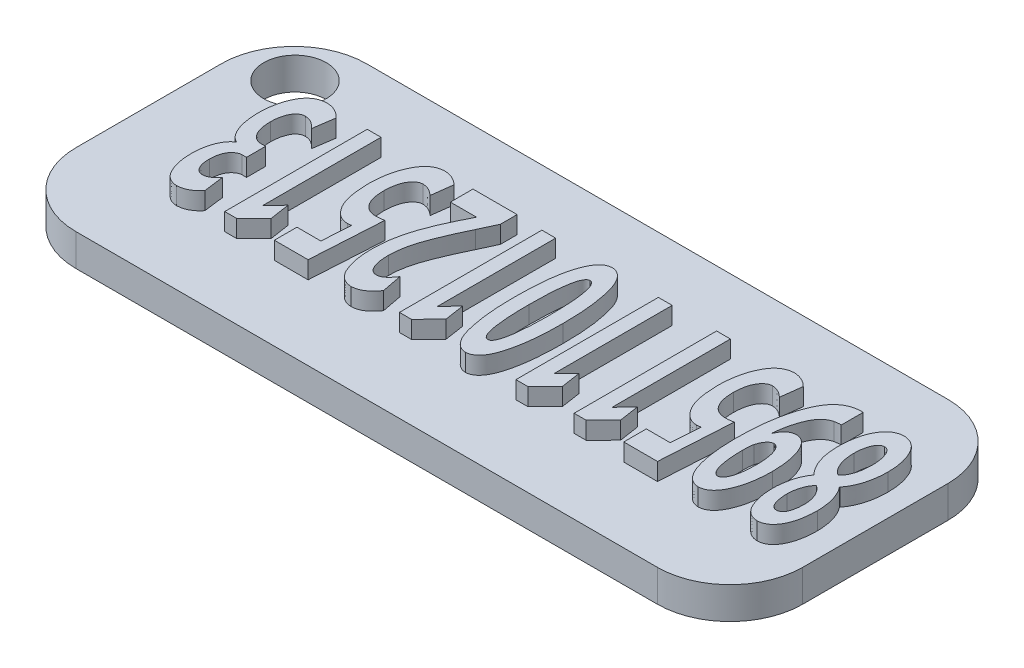
from build123d import *

# Parameters (mm, degrees)
SKETCH_1_W              = 50
SKETCH_1_H              = 20
EXTRUDE_1_DEPTH         = 2.2
FILLET_1_R              = 5
FILLET_2_R              = 5
FILLET_3_R              = 5
FILLET_4_R              = 5
SKETCH_4_R              = 2.151855383
CUT_EXTRUDE_1_DEPTH     = 3
EXTRUDE_1054_DEPTH      = 1.2
EXTRUDE_1054_DEPTH_BACK = 1.2


with BuildPart() as part:
    # Эскиз1 → Бобышка-Вытянуть1 (new body)
    with BuildSketch(Plane(origin=(0, 0, 0), x_dir=(1, 0, 0), z_dir=(0, 1, 0))):
        with Locations((25, 10)):
            Rectangle(SKETCH_1_W, SKETCH_1_H)
    extrude(amount=EXTRUDE_1_DEPTH)

    # Скругление1
    fillet_1_edges = [part.edges().sort_by_distance(p)[0] for p in [
        (0, 1.1, -20),
    ]]
    fillet(fillet_1_edges, radius=FILLET_1_R)

    # Скругление2
    fillet_2_edges = [part.edges().sort_by_distance(p)[0] for p in [
        (0, 1.1, 0),
    ]]
    fillet(fillet_2_edges, radius=FILLET_2_R)

    # Скругление3
    fillet_3_edges = [part.edges().sort_by_distance(p)[0] for p in [
        (50, 1.1, -20),
    ]]
    fillet(fillet_3_edges, radius=FILLET_3_R)

    # Скругление4
    fillet_4_edges = [part.edges().sort_by_distance(p)[0] for p in [
        (50, 1.1, 0),
    ]]
    fillet(fillet_4_edges, radius=FILLET_4_R)

    # Эскиз4 → Вырез-Вытянуть1 (cut)
    with BuildSketch(Plane(origin=(0, 2.2, 0), x_dir=(1, 0, 0), z_dir=(0, 1, 0))):
        with Locations((3.542470198, 16.528352227)):
            Circle(SKETCH_4_R)
    extrude(amount=-CUT_EXTRUDE_1_DEPTH, mode=Mode.SUBTRACT)

    # Эскиз5 → Extrude 1054 (add, two sides: drawn at the far end of the back side and taken through both)
    # profile 1 of 11: a face of its own
    with BuildSketch(Plane.XZ.offset(-2.2).offset(-EXTRUDE_1054_DEPTH_BACK)):
        with BuildLine():
            add(Edge.make_bspline(
                [(46.078309947, -9.677843866), (46.027974113, -9.605172508), (45.925734825, -9.457566573), (45.797719515, -9.21403545), (45.690766361, -8.949790128), (45.605330166, -8.667262078), (45.538818282, -8.374682095), (45.489532793, -8.076942657), (45.45786786, -7.777208198), (45.454564992, -7.576119586), (45.452912137, -7.475488811)],
                knots=[0, 0, 0, 0, 0.911528828, 1.851445597, 2.831681584, 3.849114504, 4.893651631, 5.925632796, 6.961924405, 8, 8, 8, 8], degree=3))
            add(Edge.make_bspline(
                [(45.452912137, -7.475488811), (45.456739433, -7.319432744), (45.464194853, -7.015441717), (45.526511786, -6.573878797), (45.63311746, -6.161319712), (45.753938359, -5.83962289), (45.873267915, -5.604845892), (45.977498211, -5.452969286), (46.093544961, -5.323103196), (46.221115754, -5.213766333), (46.361470193, -5.126354365), (46.514657083, -5.061353085), (46.680172404, -5.019646003), (46.795068916, -5.009135957), (46.853741958, -5.003768899)],
                knots=[0, 0, 0, 0, 1.791554521, 3.489877151, 5.107255168, 6.676714242, 7.425606061, 8.126241729, 8.785513885, 9.420356286, 10.049181088, 10.676513228, 11.324148379, 12, 12, 12, 12], degree=3))
            add(Edge.make_bspline(
                [(46.853741958, -5.003768899), (46.90797993, -5.007260305), (47.014463515, -5.014114866), (47.169787234, -5.050784431), (47.315929588, -5.110360712), (47.455258419, -5.189599), (47.583778459, -5.293674812), (47.705715522, -5.417268753), (47.817999658, -5.563759963), (47.924291395, -5.729516874), (48.016616167, -5.916192509), (48.100737096, -6.118543686), (48.169034399, -6.33794704), (48.228390088, -6.572481678), (48.272394452, -6.824061429), (48.306605506, -7.091379936), (48.326940882, -7.375267295), (48.331443098, -7.569726588), (48.333757313, -7.669681908)],
                knots=[0, 0, 0, 0, 0.776059093, 1.523610694, 2.26943235, 3.026161316, 3.806370488, 4.625991605, 5.503091466, 6.44030775, 7.436849706, 8.476373815, 9.570387437, 10.718835958, 11.933161742, 13.219262995, 14.570654791, 16, 16, 16, 16], degree=3))
            add(Edge.make_bspline(
                [(48.333757313, -7.669681908), (48.332400882, -7.773485108), (48.329714157, -7.979091408), (48.294470298, -8.282880004), (48.248183965, -8.579721921), (48.175551215, -8.86483122), (48.087174996, -9.135586497), (47.976756913, -9.385857701), (47.850277624, -9.616246555), (47.747160445, -9.753473674), (47.696502294, -9.820888941)],
                knots=[0, 0, 0, 0, 1.089978603, 2.15895528, 3.20972959, 4.244258845, 5.246508595, 6.198517637, 7.11498969, 8, 8, 8, 8], degree=3))
            Line((47.696502294, -9.820888941), (47.695145343, -9.85936227))
            add(Edge.make_bspline(
                [(47.695145343, -9.85936227), (47.747554237, -9.926459085), (47.856031089, -10.065337253), (47.992318934, -10.306361212), (48.120543883, -10.577558027), (48.235291236, -10.883599416), (48.332007715, -11.222904393), (48.400135986, -11.596003837), (48.444033938, -12.001236193), (48.450872319, -12.282433004), (48.454420985, -12.428355484)],
                knots=[0, 0, 0, 0, 0.747893007, 1.548002103, 2.428220339, 3.385024111, 4.419108458, 5.527032265, 6.716693888, 8, 8, 8, 8], degree=3))
            add(Edge.make_bspline(
                [(48.454420985, -12.428355484), (48.452674256, -12.516993812), (48.449226519, -12.691950305), (48.430923326, -12.949468758), (48.398000408, -13.197850059), (48.355874941, -13.436766086), (48.298960072, -13.665970943), (48.22900655, -13.885768002), (48.146139953, -14.095954879), (48.053448211, -14.295680741), (47.946991827, -14.478130498), (47.827908731, -14.639709615), (47.697781171, -14.778860945), (47.554387512, -14.893967333), (47.398514091, -14.984872048), (47.231251794, -15.053623861), (47.051286399, -15.097807415), (46.926883157, -15.107935165), (46.863168807, -15.113122193)],
                knots=[0, 0, 0, 0, 1.235435888, 2.438533473, 3.595508883, 4.725923701, 5.817781028, 6.884189936, 7.938117332, 8.96461166, 9.950003493, 10.876660607, 11.756436375, 12.597656396, 13.429845812, 14.262588117, 15.110167343, 16, 16, 16, 16], degree=3))
            add(Edge.make_bspline(
                [(46.863168807, -15.113122193), (46.80262288, -15.109171079), (46.684044908, -15.101432903), (46.511067483, -15.060678112), (46.347933835, -14.995360647), (46.191896755, -14.909032346), (46.047301537, -14.794897335), (45.911617757, -14.658556004), (45.784541788, -14.498597289), (45.668579213, -14.315558168), (45.563753042, -14.112223731), (45.470997983, -13.891170782), (45.394091896, -13.651866208), (45.330756558, -13.395988548), (45.279593831, -13.122797621), (45.242938773, -12.833195306), (45.217255905, -12.526213109), (45.213510802, -12.315917003), (45.211584793, -12.207767208)],
                knots=[0, 0, 0, 0, 0.789717121, 1.546644996, 2.30406014, 3.074123165, 3.86213959, 4.696104222, 5.576133471, 6.519015237, 7.51540899, 8.554319549, 9.6395583, 10.787721216, 11.987677943, 13.259577382, 14.590672234, 16, 16, 16, 16], degree=3))
            add(Edge.make_bspline(
                [(45.211584793, -12.207767208), (45.21631399, -12.061200702), (45.225433942, -11.778556663), (45.273766155, -11.372768263), (45.352120596, -11.002667897), (45.459635252, -10.669550107), (45.589719445, -10.373513923), (45.734618791, -10.113421233), (45.894005329, -9.888382936), (46.01865144, -9.764048816), (46.078854937, -9.703996008)],
                knots=[0, 0, 0, 0, 1.293490065, 2.494412024, 3.600539669, 4.62641707, 5.577396771, 6.448871158, 7.250811916, 8, 8, 8, 8], degree=3))
            Line((46.078854937, -9.703996008), (46.078309947, -9.677843866))
        make_face()
        with BuildLine():
            add(Edge.make_bspline(
                [(46.83621391, -13.800904757), (46.862390214, -13.798185585), (46.913759078, -13.792849434), (46.987088364, -13.766571208), (47.056547102, -13.729238508), (47.117966898, -13.673680896), (47.180206287, -13.610280654), (47.232947149, -13.529565327), (47.285573124, -13.438614817), (47.344553499, -13.294330749), (47.410925257, -13.095175517), (47.463520234, -12.833038866), (47.498548764, -12.547453652), (47.502265453, -12.348657789), (47.504194566, -12.245474606)],
                knots=[0, 0, 0, 0, 0.516878197, 1.014331308, 1.524422578, 2.060470795, 2.63878414, 3.270961343, 3.953097661, 4.707736148, 6.337157177, 8.083774507, 9.967318802, 12, 12, 12, 12], degree=3))
            add(Edge.make_bspline(
                [(47.504194566, -12.245474606), (47.501605234, -12.149267424), (47.496550758, -11.961467335), (47.469393374, -11.687559734), (47.419429409, -11.430678791), (47.355280098, -11.191444527), (47.271814748, -10.975113826), (47.170826099, -10.787544871), (47.053714874, -10.629827493), (46.959591571, -10.548418242), (46.914073794, -10.509048947)],
                knots=[0, 0, 0, 0, 1.22142396, 2.384266159, 3.488789828, 4.539640758, 5.524731502, 6.424298786, 7.237995119, 8, 8, 8, 8], degree=3))
            add(Edge.make_bspline(
                [(46.914073794, -10.509048947), (46.86044007, -10.548203883), (46.750645538, -10.628358636), (46.609486585, -10.785243872), (46.482183681, -10.970250236), (46.371339819, -11.186804007), (46.277961057, -11.434662914), (46.214225457, -11.716286991), (46.172416068, -12.028695365), (46.165451114, -12.247841318), (46.161811212, -12.362367538)],
                knots=[0, 0, 0, 0, 0.764838737, 1.565714712, 2.420999668, 3.352265673, 4.366974192, 5.470323704, 6.677984882, 8, 8, 8, 8], degree=3))
            add(Edge.make_bspline(
                [(46.161811212, -12.362367538), (46.163759344, -12.457382745), (46.167514338, -12.640523049), (46.202428312, -12.9042703), (46.256201504, -13.146406235), (46.3292193, -13.363319376), (46.421100573, -13.54734881), (46.538282039, -13.686539035), (46.67973401, -13.7773093), (46.784720718, -13.793083723), (46.83621391, -13.800904757)],
                knots=[0, 0, 0, 0, 1.321228345, 2.546646677, 3.694107777, 4.76689393, 5.725035891, 6.536813707, 7.27454525, 8, 8, 8, 8], degree=3))
        make_face(mode=Mode.SUBTRACT)
        with BuildLine():
            add(Edge.make_bspline(
                [(46.886500259, -6.293647279), (46.83538083, -6.301938363), (46.734376801, -6.318320253), (46.600140532, -6.408312885), (46.493740845, -6.543789202), (46.41679896, -6.722317663), (46.358261152, -6.92709015), (46.311903706, -7.152013712), (46.285864996, -7.392535246), (46.283622758, -7.558383626), (46.282474884, -7.64328673)],
                knots=[0, 0, 0, 0, 0.765528405, 1.512564887, 2.346431841, 3.307864738, 4.394490714, 5.524415916, 6.732669124, 8, 8, 8, 8], degree=3))
            add(Edge.make_bspline(
                [(46.282474884, -7.64328673), (46.285542594, -7.725718472), (46.291533991, -7.886711995), (46.322755467, -8.121747951), (46.368092179, -8.344452345), (46.434989814, -8.55067455), (46.511234044, -8.737323134), (46.60109943, -8.897440638), (46.696643827, -9.032946341), (46.775094048, -9.101929862), (46.81226382, -9.134614305)],
                knots=[0, 0, 0, 0, 1.216519099, 2.375925702, 3.494449087, 4.564888535, 5.570675503, 6.463263841, 7.271893284, 8, 8, 8, 8], degree=3))
            add(Edge.make_bspline(
                [(46.81226382, -9.134614305), (46.862439152, -9.096350175), (46.963589503, -9.019212066), (47.096313583, -8.876918569), (47.213065342, -8.713564267), (47.315895318, -8.52958974), (47.398878962, -8.323302575), (47.458545593, -8.094677067), (47.497098, -7.844424879), (47.501769248, -7.669832657), (47.504194566, -7.579184154)],
                knots=[0, 0, 0, 0, 0.854607252, 1.722835104, 2.626488507, 3.572752242, 4.57465509, 5.633219383, 6.771164507, 8, 8, 8, 8], degree=3))
            add(Edge.make_bspline(
                [(47.504194566, -7.579184154), (47.503195757, -7.499277873), (47.501255068, -7.344019773), (47.473234473, -7.117775601), (47.431519103, -6.903753043), (47.369090488, -6.707727668), (47.290569229, -6.53547269), (47.182295761, -6.403004689), (47.043184988, -6.318466445), (46.940284878, -6.303102084), (46.887678615, -6.295247266)],
                knots=[0, 0, 0, 0, 1.230812713, 2.391472128, 3.50850541, 4.586815455, 5.557221012, 6.409314627, 7.186784035, 8, 8, 8, 8], degree=3))
            Line((46.887678615, -6.295247266), (46.886500259, -6.293647279))
        make_face(mode=Mode.SUBTRACT)
    # profile 2 of 11: a face of its own
    with BuildSketch(Plane.XZ.offset(-2.2).offset(-EXTRUDE_1054_DEPTH_BACK)):
        with BuildLine():
            add(Edge.make_bspline(
                [(44.04725437, -15.11174683), (43.987385205, -15.114070393), (43.868898808, -15.118668932), (43.693434551, -15.103937408), (43.523252435, -15.077828695), (43.358741609, -15.039003764), (43.201388033, -14.983318238), (43.050111553, -14.915129471), (42.903936107, -14.834674512), (42.766996185, -14.736787277), (42.632629914, -14.629426485), (42.508059907, -14.504726533), (42.38788946, -14.367318384), (42.273368197, -14.217136563), (42.16508345, -14.052358087), (42.066568067, -13.872002181), (41.96939987, -13.68052939), (41.851289199, -13.402249017), (41.717343953, -13.031760823), (41.577455337, -12.561667209), (41.462107324, -12.061386408), (41.365507994, -11.533031322), (41.293318956, -10.975995836), (41.240314731, -10.390514117), (41.210397464, -9.775330417), (41.207191415, -9.35523444), (41.205550872, -9.140270414)],
                knots=[0, 0, 0, 0, 0.587702947, 1.163116348, 1.725075362, 2.277262808, 2.819713187, 3.360969282, 3.905101247, 4.454524283, 5.011482261, 5.591737658, 6.182009412, 6.802709751, 7.444427068, 8.115602503, 8.819201884, 9.551563824, 11.081795736, 12.684480665, 14.363626865, 16.119590269, 17.955514458, 19.875934814, 21.889706872, 24, 24, 24, 24], degree=3))
            add(Edge.make_bspline(
                [(41.205550872, -9.140270414), (41.207264897, -8.991309733), (41.210614758, -8.700183418), (41.228928778, -8.27442403), (41.26139615, -7.870179001), (41.303851059, -7.487012124), (41.35985007, -7.12516581), (41.429753321, -6.785560877), (41.510350616, -6.467461477), (41.603134364, -6.172814895), (41.708826173, -5.906123561), (41.827749924, -5.671195277), (41.958955197, -5.470530026), (42.102547312, -5.302101472), (42.26283362, -5.173038944), (42.433532632, -5.075831142), (42.618009403, -5.01296775), (42.746684608, -5.000605939), (42.81188601, -4.994342049)],
                knots=[0, 0, 0, 0, 1.488694986, 2.909481093, 4.257746305, 5.540848802, 6.761339651, 7.915469393, 9.004609899, 10.039448099, 11.000449599, 11.868389147, 12.666188125, 13.391717201, 14.070478316, 14.711614416, 15.347158253, 16, 16, 16, 16], degree=3))
            add(Edge.make_bspline(
                [(42.81188601, -4.994342049), (42.873943174, -5.000099892), (42.997342197, -5.011549209), (43.174435585, -5.071753842), (43.341841896, -5.156147597), (43.497681637, -5.27312241), (43.642287555, -5.41903082), (43.776639778, -5.595135643), (43.901300582, -5.799757373), (44.011533243, -6.03278609), (44.113476948, -6.28555358), (44.198583084, -6.556030295), (44.274785722, -6.839444532), (44.337084136, -7.137093239), (44.382818759, -7.449561619), (44.419726254, -7.775163248), (44.439445614, -8.115654083), (44.444116993, -8.347137517), (44.446501695, -8.465307997)],
                knots=[0, 0, 0, 0, 0.71661271, 1.42496533, 2.141431373, 2.872130828, 3.661492946, 4.503891963, 5.421382964, 6.41994004, 7.473922347, 8.56282292, 9.6881508, 10.858187346, 12.067902601, 13.329498283, 14.63672978, 16, 16, 16, 16], degree=3))
            add(Edge.make_bspline(
                [(44.446501695, -8.465307997), (44.444301581, -8.579725962), (44.440018776, -8.802455229), (44.418138685, -9.126841338), (44.389744776, -9.432845618), (44.346232134, -9.719112434), (44.291514129, -9.986576149), (44.226515668, -10.234971415), (44.149036141, -10.464286834), (44.061521886, -10.673296099), (43.963022591, -10.859813171), (43.86081538, -11.024451663), (43.750302846, -11.165118524), (43.632325733, -11.27981019), (43.50792487, -11.371672429), (43.375998762, -11.435440305), (43.238321206, -11.480471442), (43.142806007, -11.486436477), (43.094691492, -11.489441284)],
                knots=[0, 0, 0, 0, 1.529770763, 2.977895321, 4.345668482, 5.637335493, 6.846838563, 7.994249315, 9.067689445, 10.080490039, 11.020068362, 11.884879202, 12.668265517, 13.405073479, 14.079029672, 14.725341234, 15.357907549, 16, 16, 16, 16], degree=3))
            add(Edge.make_bspline(
                [(43.094691492, -11.489441284), (43.044787182, -11.486183321), (42.945933546, -11.479729739), (42.803226891, -11.439100379), (42.670705849, -11.373559165), (42.548260623, -11.283451948), (42.439085027, -11.168339541), (42.333351592, -11.038338918), (42.241947327, -10.886319281), (42.190018525, -10.776615668), (42.163318771, -10.720210373)],
                knots=[0, 0, 0, 0, 0.935406275, 1.852912324, 2.759079899, 3.694486174, 4.685786001, 5.725263117, 6.830419519, 8, 8, 8, 8], degree=3))
            Line((42.163318771, -10.720210373), (42.143203863, -10.732850085))
            add(Edge.make_bspline(
                [(42.143203863, -10.732850085), (42.152913081, -10.826145832), (42.171961613, -11.009182943), (42.213021068, -11.276889607), (42.256329034, -11.533427069), (42.312327657, -11.777714281), (42.373431464, -12.010753199), (42.443989973, -12.232601603), (42.520328195, -12.443143418), (42.604992277, -12.640929958), (42.696024941, -12.824197987), (42.797560211, -12.98838531), (42.907535712, -13.132919259), (43.024857499, -13.258958894), (43.151200313, -13.365300223), (43.286637025, -13.450625789), (43.428878747, -13.518420365), (43.529094466, -13.547109732), (43.579231551, -13.561462782)],
                knots=[0, 0, 0, 0, 1.339989936, 2.628928885, 3.868993049, 5.056241457, 6.208438896, 7.310307185, 8.381264534, 9.407037606, 10.382860463, 11.30231499, 12.160773156, 12.973890012, 13.757980097, 14.51278177, 15.255957167, 16, 16, 16, 16], degree=3))
            add(Edge.make_bspline(
                [(43.579231551, -13.561462782), (43.61258245, -13.566861786), (43.67367764, -13.576752169), (43.756732427, -13.593836438), (43.824452891, -13.601489775), (43.891708091, -13.613413366), (43.965642464, -13.61504435), (44.021131507, -13.605697441), (44.048688651, -13.601055549)],
                knots=[0, 0, 0, 0, 1.282317147, 2.349064382, 3.21602214, 3.867087612, 4.940746315, 6, 6, 6, 6], degree=3))
            Line((44.048688651, -13.601055549), (44.04725437, -15.11174683))
        make_face()
        with BuildLine():
            add(Edge.make_bspline(
                [(42.844590917, -6.304677798), (42.81632972, -6.308919917), (42.759015095, -6.317523072), (42.678836933, -6.357293238), (42.605990003, -6.416423603), (42.536602226, -6.493216758), (42.476050485, -6.592472346), (42.419178939, -6.710531156), (42.368846462, -6.849011498), (42.308227289, -7.066665145), (42.244553984, -7.373100249), (42.194071408, -7.777220869), (42.161821034, -8.225345058), (42.15785408, -8.538776352), (42.155777292, -8.702864602)],
                knots=[0, 0, 0, 0, 0.388324956, 0.787535614, 1.2030177, 1.664837744, 2.193361997, 2.784441419, 3.452382468, 4.202091393, 5.868356787, 7.720494359, 9.759583653, 12, 12, 12, 12], degree=3))
            add(Edge.make_bspline(
                [(42.155777292, -8.702864602), (42.155368544, -8.74812072), (42.154596287, -8.833624136), (42.15968612, -8.954239716), (42.162435199, -9.060539025), (42.170279424, -9.177455748), (42.179085395, -9.300512339), (42.199485933, -9.390539813), (42.208567648, -9.430617376)],
                knots=[0, 0, 0, 0, 1.11380462, 2.104336476, 2.971181265, 3.730606527, 4.989733304, 6, 6, 6, 6], degree=3))
            add(Edge.make_bspline(
                [(42.208567648, -9.430617376), (42.238302449, -9.525684566), (42.295931093, -9.709933092), (42.4157911, -9.915830309), (42.528538944, -10.050337156), (42.621005158, -10.125337554), (42.723563966, -10.173398169), (42.796336215, -10.182241067), (42.832625079, -10.186650697)],
                knots=[0, 0, 0, 0, 1.717293694, 3.328265295, 4.075010403, 4.73980506, 5.371586794, 6, 6, 6, 6], degree=3))
            add(Edge.make_bspline(
                [(42.832625079, -10.186650697), (42.857327254, -10.184568066), (42.906667609, -10.1804082), (42.978465354, -10.154699735), (43.044277372, -10.112341419), (43.106396021, -10.054870548), (43.165721311, -9.984224083), (43.221107135, -9.897287482), (43.271162554, -9.795137333), (43.33631677, -9.632755834), (43.402506594, -9.394999705), (43.459803499, -9.070602549), (43.494534602, -8.697313717), (43.499373301, -8.432077134), (43.501931386, -8.291853969)],
                knots=[0, 0, 0, 0, 0.413789282, 0.826506569, 1.261562931, 1.716042024, 2.238855857, 2.802250335, 3.437615293, 4.141140511, 5.729823065, 7.558733105, 9.652026376, 12, 12, 12, 12], degree=3))
            add(Edge.make_bspline(
                [(43.501931386, -8.291853969), (43.499172297, -8.153522521), (43.493908565, -7.889616713), (43.460775977, -7.513375446), (43.405536667, -7.177101272), (43.340129957, -6.924955276), (43.279157951, -6.746836863), (43.227842301, -6.634724435), (43.176350338, -6.536377609), (43.117340877, -6.457508469), (43.056964627, -6.392355076), (42.99033886, -6.347000991), (42.91982955, -6.316280085), (42.870621648, -6.309816763), (42.845822668, -6.306559485)],
                knots=[0, 0, 0, 0, 2.244031887, 4.281116543, 6.121417338, 7.765846703, 8.501017567, 9.171798035, 9.76494997, 10.29714384, 10.765780613, 11.198437351, 11.596041788, 12, 12, 12, 12], degree=3))
            Line((42.845822668, -6.306559485), (42.844590917, -6.304677798))
        make_face(mode=Mode.SUBTRACT)
    # profile 3 of 11: a face of its own
    with BuildSketch(Plane.XZ.offset(-2.2).offset(-EXTRUDE_1054_DEPTH_BACK)):
        with BuildLine():
            add(Edge.make_bspline(
                [(40.192335424, -10.097629571), (40.108779367, -10.080350986), (39.928861905, -10.043145792), (39.745130929, -10.038375834), (39.646727056, -10.035821107)],
                knots=[0, 0, 0, 0, 0.928826533, 2, 2, 2, 2], degree=3))
            add(Edge.make_bspline(
                [(39.646727056, -10.035821107), (39.596356053, -10.037144258), (39.498842118, -10.039705763), (39.357107939, -10.063141988), (39.225526757, -10.100461888), (39.102393915, -10.151947208), (38.989423473, -10.218450867), (38.884167932, -10.297443649), (38.791440863, -10.394209158), (38.706195987, -10.502836195), (38.633369841, -10.627502307), (38.566555859, -10.762910831), (38.512386723, -10.912277426), (38.469995342, -11.074174259), (38.433102138, -11.247566327), (38.409926726, -11.434895562), (38.394464745, -11.634355423), (38.392221711, -11.771586486), (38.391070716, -11.842005452)],
                knots=[0, 0, 0, 0, 0.971191819, 1.880143916, 2.762839131, 3.60505127, 4.447263409, 5.286327734, 6.135146923, 7.025222593, 7.94430753, 8.914969409, 9.935323239, 11.002990034, 12.142007005, 13.352662052, 14.641540791, 16, 16, 16, 16], degree=3))
            add(Edge.make_bspline(
                [(38.391070716, -11.842005452), (38.393043981, -11.909272993), (38.396884389, -12.040190474), (38.411460772, -12.23096965), (38.436079789, -12.409638534), (38.467810303, -12.575884139), (38.50725334, -12.730478322), (38.556081545, -12.872815282), (38.611926704, -13.004160281), (38.678287624, -13.120952078), (38.750159379, -13.224092842), (38.823488973, -13.316422958), (38.902159433, -13.393647183), (38.984829667, -13.455748737), (39.067355654, -13.509965552), (39.157602931, -13.541523956), (39.248784571, -13.566999866), (39.311573168, -13.569587136), (39.343182505, -13.570889631)],
                knots=[0, 0, 0, 0, 1.492946742, 2.905603862, 4.242536531, 5.492208905, 6.658933463, 7.7788985, 8.82796704, 9.820667976, 10.75276788, 11.615096908, 12.433471051, 13.189229796, 13.909019935, 14.610757751, 15.300620973, 16, 16, 16, 16], degree=3))
            add(Edge.make_bspline(
                [(39.343182505, -13.570889631), (39.38983853, -13.568380356), (39.482097569, -13.56341844), (39.617626699, -13.533825924), (39.747972164, -13.488642345), (39.908712456, -13.409054131), (40.087661862, -13.294393111), (40.206952933, -13.179946467), (40.263243007, -13.12594234)],
                knots=[0, 0, 0, 0, 0.801470045, 1.584851196, 2.37349572, 3.165310909, 4.662390589, 6, 6, 6, 6], degree=3))
            Line((40.263243007, -13.12594234), (40.449658954, -14.587103996))
            add(Edge.make_bspline(
                [(40.449658954, -14.587103996), (40.417096041, -14.621108057), (40.350838838, -14.690297629), (40.2359918, -14.783586466), (40.105123663, -14.867027635), (39.962626792, -14.946663917), (39.808394683, -15.015512651), (39.64214658, -15.060505063), (39.470306048, -15.095572759), (39.352168796, -15.099711688), (39.292277519, -15.101809973)],
                knots=[0, 0, 0, 0, 0.867626664, 1.765398496, 2.720085674, 3.726414318, 4.774902414, 5.823966795, 6.896830548, 8, 8, 8, 8], degree=3))
            add(Edge.make_bspline(
                [(39.292277519, -15.101809973), (39.221510791, -15.095970858), (39.082375373, -15.084490493), (38.881797156, -15.02715985), (38.69309556, -14.943712842), (38.515668747, -14.83081222), (38.350519784, -14.687994683), (38.199822831, -14.513981942), (38.060076919, -14.312731964), (37.933175297, -14.084880226), (37.819987239, -13.835916731), (37.719541463, -13.570860738), (37.634882259, -13.291113855), (37.565814728, -12.997565106), (37.510807312, -12.690453339), (37.471785794, -12.369443935), (37.446831675, -12.034072997), (37.442864076, -11.805599251), (37.440844297, -11.689290491)],
                knots=[0, 0, 0, 0, 0.800118372, 1.57312353, 2.341915381, 3.123472314, 3.938586515, 4.798407496, 5.715777283, 6.700728512, 7.739066045, 8.801352045, 9.899074363, 11.036803875, 12.204674243, 13.420209821, 14.686710393, 16, 16, 16, 16], degree=3))
            add(Edge.make_bspline(
                [(37.440844297, -11.689290491), (37.444230945, -11.562928248), (37.450775258, -11.318747534), (37.476688876, -10.965686938), (37.517892952, -10.637743387), (37.573539342, -10.33543868), (37.64374808, -10.057774711), (37.725222218, -9.804857657), (37.822605491, -9.576898803), (37.937227253, -9.376389846), (38.059134548, -9.199215643), (38.187289425, -9.045129367), (38.322065034, -8.915482301), (38.462376667, -8.808978448), (38.607735816, -8.723793371), (38.761174563, -8.667597532), (38.919204195, -8.631858513), (39.02687709, -8.627672895), (39.081116092, -8.625564437)],
                knots=[0, 0, 0, 0, 1.587176406, 3.067038503, 4.44328291, 5.735702164, 6.924301074, 8.037326695, 9.069410064, 10.030633494, 10.932524697, 11.767135362, 12.542965892, 13.275314645, 13.975181296, 14.649441249, 15.319671309, 16, 16, 16, 16], degree=3))
            add(Edge.make_bspline(
                [(39.081116092, -8.625564437), (39.127902894, -8.626817487), (39.219370871, -8.629267193), (39.307616765, -8.653378888), (39.350723985, -8.665157205)],
                knots=[0, 0, 0, 0, 1.023020369, 2, 2, 2, 2], degree=3))
            Line((39.350723985, -8.665157205), (39.220939099, -6.666668815))
            Line((39.220939099, -6.666668815), (37.574777364, -6.666668815))
            Line((37.574777364, -6.666668815), (37.574777364, -5.113122193))
            Line((37.574777364, -5.113122193), (39.896413365, -5.113122193))
            Line((39.896413365, -5.113122193), (40.192335424, -10.097629571))
        make_face()
    # profile 4 of 11: a face of its own
    with BuildSketch(Plane.XZ.offset(-2.2).offset(-EXTRUDE_1054_DEPTH_BACK)):
        Polygon((34.158790569, -5.11618776), (34.977041097, -5.11618776), (36.164045302, -6.304029702), (35.958186478, -7.670436793), (35.121885006, -6.784268761), (35.10901883, -6.784268761), (35.10901883, -14.916163641), (34.158790569, -14.916163641), align=None)
    # profile 5 of 11: a face of its own
    with BuildSketch(Plane.XZ.offset(-2.2).offset(-EXTRUDE_1054_DEPTH_BACK)):
        Polygon((30.152756649, -5.11618776), (30.971007177, -5.11618776), (32.158011381, -6.304029702), (31.952152558, -7.670436793), (31.115851086, -6.784268761), (31.10298491, -6.784268761), (31.10298491, -14.916163641), (30.152756649, -14.916163641), align=None)
    # profile 6 of 11: a face of its own
    with BuildSketch(Plane.XZ.offset(-2.2).offset(-EXTRUDE_1054_DEPTH_BACK)):
        with BuildLine():
            add(Edge.make_bspline(
                [(26.809299518, -15.101809973), (26.746303194, -15.09638161), (26.619917897, -15.085491049), (26.437337927, -15.01868558), (26.26818752, -14.908811333), (26.110374921, -14.759422894), (25.968174728, -14.566701686), (25.833806264, -14.33684957), (25.712767778, -14.065712383), (25.602795043, -13.755863084), (25.502735422, -13.409193068), (25.420202683, -13.025732465), (25.34610482, -12.608293788), (25.286865972, -12.15591364), (25.23998078, -11.66856733), (25.206820786, -11.146674152), (25.185798893, -10.589663148), (25.182906213, -10.206781024), (25.181415192, -10.009425929)],
                knots=[0, 0, 0, 0, 0.529751383, 1.062804646, 1.61385316, 2.215574753, 2.879125032, 3.620281667, 4.450123201, 5.370886135, 6.382468459, 7.480938196, 8.666507297, 9.945632662, 11.315014225, 12.78147403, 14.341023359, 16, 16, 16, 16], degree=3))
            add(Edge.make_bspline(
                [(25.181415192, -10.009425929), (25.181594802, -9.83846625), (25.181946857, -9.503367638), (25.200712717, -9.011224948), (25.225382227, -8.539569403), (25.264918328, -8.08868405), (25.317668467, -7.659276576), (25.381631825, -7.250492679), (25.457097023, -6.862499825), (25.540937144, -6.497128173), (25.641167264, -6.164136588), (25.754138819, -5.869060173), (25.886371647, -5.617603335), (26.032954584, -5.408078929), (26.194328054, -5.238370761), (26.374813205, -5.116430621), (26.569858099, -5.031316429), (26.708366208, -5.014266033), (26.77832348, -5.005654268)],
                knots=[0, 0, 0, 0, 1.462772537, 2.867185112, 4.213715228, 5.503936185, 6.739261869, 7.915146218, 9.043642378, 10.121075315, 11.121384378, 12.017154031, 12.820647149, 13.545818879, 14.199911066, 14.811456886, 15.399694113, 16, 16, 16, 16], degree=3))
            add(Edge.make_bspline(
                [(26.77832348, -5.005654268), (26.845668436, -5.012484701), (26.979858378, -5.026094857), (27.170722285, -5.105203556), (27.348561052, -5.221532839), (27.510469576, -5.383463747), (27.659394634, -5.584916244), (27.791812968, -5.829877383), (27.914628312, -6.114231056), (28.021461623, -6.439779921), (28.116150161, -6.799585126), (28.198000263, -7.188714477), (28.270812963, -7.604092372), (28.325359029, -8.047913084), (28.371124371, -8.5187241), (28.40243751, -9.017369504), (28.421621423, -9.54295639), (28.423360712, -9.902570919), (28.424251385, -10.086726094)],
                knots=[0, 0, 0, 0, 0.566917839, 1.129626877, 1.717802694, 2.346074211, 3.045200701, 3.819275146, 4.683807342, 5.648743943, 6.699322103, 7.813300624, 8.993971249, 10.246825329, 11.574997533, 12.974020352, 14.450424652, 16, 16, 16, 16], degree=3))
            add(Edge.make_bspline(
                [(28.424251385, -10.086726094), (28.424015911, -10.25831122), (28.423554324, -10.594660491), (28.405591368, -11.088138692), (28.378178113, -11.560997764), (28.337230808, -12.012552367), (28.282027131, -12.443776648), (28.216742309, -12.853881675), (28.139866611, -13.243461663), (28.050755892, -13.608118868), (27.950470975, -13.942186433), (27.831398671, -14.236088467), (27.701081254, -14.489470684), (27.553941621, -14.700168368), (27.39079744, -14.867821763), (27.211822039, -14.991663615), (27.017450266, -15.075757432), (26.879662726, -15.093092731), (26.810374768, -15.101809973)],
                knots=[0, 0, 0, 0, 1.464767554, 2.871306572, 4.215045025, 5.508116909, 6.741261956, 7.92587706, 9.052808243, 10.130273157, 11.12984833, 12.027539368, 12.833925245, 13.557426221, 14.213772112, 14.819481535, 15.406363497, 16, 16, 16, 16], degree=3))
            Line((26.810374768, -15.101809973), (26.809299518, -15.101809973))
        make_face()
        with BuildLine():
            add(Edge.make_bspline(
                [(26.802783577, -13.570889631), (26.82972821, -13.566913579), (26.885599706, -13.55866897), (26.963757307, -13.510949639), (27.033416909, -13.436461328), (27.097389299, -13.335455549), (27.156783047, -13.208647312), (27.210771424, -13.054997071), (27.258909173, -12.874474472), (27.303929133, -12.66755349), (27.343049012, -12.433448541), (27.375946513, -12.172314412), (27.407282509, -11.884590633), (27.427221837, -11.569314118), (27.450333471, -11.22763153), (27.461250034, -10.858511079), (27.471886722, -10.461974123), (27.473296076, -10.188545351), (27.474024966, -10.047133326)],
                knots=[0, 0, 0, 0, 0.348295693, 0.722214362, 1.152022054, 1.655502919, 2.257207495, 2.954417897, 3.752591885, 4.664981709, 5.684162841, 6.811961843, 8.058606191, 9.415432032, 10.884928106, 12.474287767, 14.176570434, 16, 16, 16, 16], degree=3))
            add(Edge.make_bspline(
                [(27.474024966, -10.047133326), (27.472647484, -9.905720785), (27.469983941, -9.632281081), (27.457854317, -9.235723213), (27.44369677, -8.866717887), (27.42325985, -8.524723037), (27.396355521, -8.209903763), (27.367586717, -7.921739256), (27.331021635, -7.661002482), (27.293055445, -7.427248661), (27.247387342, -7.22174442), (27.199859787, -7.04199042), (27.143480766, -6.891224861), (27.085920537, -6.764364414), (27.020432467, -6.666759457), (26.952339235, -6.591936222), (26.873943998, -6.546845111), (26.81838881, -6.539922528), (26.791521069, -6.536574611)],
                knots=[0, 0, 0, 0, 1.828192425, 3.535049952, 5.128793054, 6.602054755, 7.963618568, 9.213457478, 10.345225998, 11.367018811, 12.273810474, 13.066196316, 13.7679736, 14.353056012, 14.862318632, 15.281738881, 15.652632741, 16, 16, 16, 16], degree=3))
            add(Edge.make_bspline(
                [(26.791521069, -6.536574611), (26.763281549, -6.540357152), (26.705169626, -6.548140951), (26.625058403, -6.598099153), (26.554955239, -6.675722822), (26.489171698, -6.779129337), (26.429992486, -6.910851832), (26.375442771, -7.069801856), (26.330227642, -7.257708958), (26.286879288, -7.47144033), (26.249851345, -7.711195986), (26.217924571, -7.975298625), (26.192610692, -8.263370431), (26.169324327, -8.574425254), (26.153376197, -8.908908887), (26.139662779, -9.267121362), (26.132286179, -9.649288884), (26.131860527, -9.91201243), (26.131641611, -10.047133326)],
                knots=[0, 0, 0, 0, 0.365144164, 0.751401903, 1.188481301, 1.711676837, 2.330067746, 3.052575452, 3.882751645, 4.828291963, 5.87357693, 7.020192641, 8.269339261, 9.614396851, 11.055335144, 12.60115741, 14.251947096, 16, 16, 16, 16], degree=3))
            add(Edge.make_bspline(
                [(26.131641611, -10.047133326), (26.131628421, -10.186029654), (26.131602814, -10.455688364), (26.142103752, -10.847230506), (26.155246919, -11.21300133), (26.170654901, -11.553232374), (26.19620508, -11.867383211), (26.223590908, -12.156693129), (26.256921734, -12.42027127), (26.296802013, -12.657820879), (26.33875979, -12.869029514), (26.387317507, -13.052446275), (26.440806828, -13.208257337), (26.501401781, -13.335639631), (26.564090894, -13.438174671), (26.634453448, -13.51262204), (26.712823643, -13.561383273), (26.769565061, -13.567777839), (26.797177179, -13.570889631)],
                knots=[0, 0, 0, 0, 1.790021536, 3.475217123, 5.04755471, 6.507297142, 7.864016094, 9.109190405, 10.252463025, 11.287084988, 12.2131664, 13.026557634, 13.73103331, 14.332422383, 14.842437598, 15.272019921, 15.645742526, 16, 16, 16, 16], degree=3))
            Line((26.797177179, -13.570889631), (26.802783577, -13.570889631))
        make_face(mode=Mode.SUBTRACT)
    # profile 7 of 11: a face of its own
    with BuildSketch(Plane.XZ.offset(-2.2).offset(-EXTRUDE_1054_DEPTH_BACK)):
        Polygon((22.140688809, -5.11618776), (22.958939337, -5.11618776), (24.145943541, -6.304029702), (23.940084718, -7.670436793), (23.103783246, -6.784268761), (23.09091707, -6.784268761), (23.09091707, -14.916163641), (22.140688809, -14.916163641), align=None)
    # profile 8 of 11: a face of its own
    with BuildSketch(Plane.XZ.offset(-2.2).offset(-EXTRUDE_1054_DEPTH_BACK)):
        with BuildLine():
            Line((19.107139352, -13.43891374), (19.107139352, -13.412698997))
            Line((19.107139352, -13.412698997), (18.701854793, -12.600041979))
            add(Edge.make_bspline(
                [(18.701854793, -12.600041979), (18.612929372, -12.419784379), (18.435565571, -12.060256443), (18.199966582, -11.508368953), (17.982816976, -10.952225293), (17.784910155, -10.389010669), (17.622791937, -9.80923383), (17.503509483, -9.208895796), (17.431758745, -8.585769802), (17.417773329, -8.163201374), (17.410674697, -7.94871665)],
                knots=[0, 0, 0, 0, 0.990000417, 1.974578639, 2.954815301, 3.930951325, 4.914170604, 5.917805251, 6.943132196, 8, 8, 8, 8], degree=3))
            add(Edge.make_bspline(
                [(17.410674697, -7.94871665), (17.411730732, -7.847512123), (17.413804983, -7.648727496), (17.430968138, -7.35684135), (17.459288835, -7.076944395), (17.497564385, -6.809787887), (17.551326877, -6.55579111), (17.614715279, -6.31451144), (17.690528215, -6.085387324), (17.77612098, -5.870150969), (17.871358463, -5.671317756), (17.985929283, -5.499017139), (18.109945149, -5.350219304), (18.247795384, -5.226583556), (18.399848033, -5.130154268), (18.564314305, -5.057635962), (18.741616427, -5.008712326), (18.865236906, -4.9992014), (18.92839745, -4.994342049)],
                knots=[0, 0, 0, 0, 1.328268938, 2.608968716, 3.836028302, 5.020081098, 6.149277671, 7.241722599, 8.292936611, 9.314608851, 10.281114086, 11.180220832, 12.023041171, 12.817659807, 13.600242319, 14.375794263, 15.170155976, 16, 16, 16, 16], degree=3))
            add(Edge.make_bspline(
                [(18.92839745, -4.994342049), (18.997826928, -4.999113566), (19.135954849, -5.00860636), (19.337940041, -5.061019833), (19.530419007, -5.144939175), (19.709753644, -5.259854913), (19.878897952, -5.392117958), (20.030688365, -5.543249595), (20.173371541, -5.702373248), (20.252048394, -5.820967972), (20.291519872, -5.880465893)],
                knots=[0, 0, 0, 0, 0.985664517, 1.960950769, 2.943222004, 3.95259574, 4.974687667, 5.98350994, 6.988344835, 8, 8, 8, 8], degree=3))
            Line((20.291519872, -5.880465893), (20.02707097, -7.265341875))
            add(Edge.make_bspline(
                [(20.02707097, -7.265341875), (19.967095563, -7.178558596), (19.846650291, -7.004276564), (19.666049854, -6.81211633), (19.50847802, -6.67994093), (19.383553674, -6.608143847), (19.254186467, -6.559141497), (19.165103056, -6.550372033), (19.120705177, -6.54600146)],
                knots=[0, 0, 0, 0, 1.582334621, 3.177714578, 3.942567127, 4.661203227, 5.332763131, 6, 6, 6, 6], degree=3))
            add(Edge.make_bspline(
                [(19.120705177, -6.54600146), (19.088482714, -6.548721479), (19.025661086, -6.554024488), (18.935405943, -6.579653192), (18.851754915, -6.617185792), (18.774600628, -6.669468698), (18.704992722, -6.735992244), (18.642353073, -6.816118847), (18.587961314, -6.909881874), (18.521452962, -7.054145091), (18.457510206, -7.258600953), (18.397479175, -7.525064223), (18.367574168, -7.819839997), (18.363189023, -8.02470904), (18.360901116, -8.131597529)],
                knots=[0, 0, 0, 0, 0.601836392, 1.173353593, 1.739801269, 2.305399607, 2.902308936, 3.528308839, 4.1956223, 4.919224413, 6.486931643, 8.178903271, 10.006378869, 12, 12, 12, 12], degree=3))
            add(Edge.make_bspline(
                [(18.360901116, -8.131597529), (18.366432249, -8.297159089), (18.377650984, -8.63296573), (18.456415062, -9.140888643), (18.573232378, -9.660546343), (18.716171327, -10.09726387), (18.847835213, -10.456615579), (18.958214335, -10.740326221), (19.076112241, -11.03635068), (19.206997766, -11.343113524), (19.345816194, -11.661448072), (19.49605149, -11.990196675), (19.653352389, -12.331639541), (19.765095, -12.561780803), (19.822062772, -12.679109678)],
                knots=[0, 0, 0, 0, 1.237381374, 2.509766652, 3.835247766, 5.215605365, 5.940929029, 6.696510371, 7.491301513, 8.322899782, 9.18968005, 10.087482787, 11.024974951, 12, 12, 12, 12], degree=3))
            Line((19.822062772, -12.679109678), (20.361591559, -13.843082543))
            Line((20.361591559, -13.843082543), (20.361591559, -14.99245852))
            Line((20.361591559, -14.99245852), (17.32060962, -14.99245852))
            Line((17.32060962, -14.99245852), (17.32060962, -13.43891374))
            Line((17.32060962, -13.43891374), (19.107139352, -13.43891374))
        make_face()
    # profile 9 of 11: a face of its own
    with BuildSketch(Plane.XZ.offset(-2.2).offset(-EXTRUDE_1054_DEPTH_BACK)):
        with BuildLine():
            add(Edge.make_bspline(
                [(16.156131903, -10.097629571), (16.072575847, -10.080350986), (15.892658384, -10.043145792), (15.708927409, -10.038375834), (15.610523536, -10.035821107)],
                knots=[0, 0, 0, 0, 0.928826533, 2, 2, 2, 2], degree=3))
            add(Edge.make_bspline(
                [(15.610523536, -10.035821107), (15.560152532, -10.037144258), (15.462638598, -10.039705763), (15.320904419, -10.063141988), (15.189323237, -10.100461888), (15.066190394, -10.151947208), (14.953219953, -10.218450867), (14.847964412, -10.297443649), (14.755237343, -10.394209158), (14.669992466, -10.502836195), (14.597166321, -10.627502307), (14.530352339, -10.762910831), (14.476183203, -10.912277426), (14.433791821, -11.074174259), (14.396898618, -11.247566327), (14.373723205, -11.434895562), (14.358261225, -11.634355423), (14.35601819, -11.771586486), (14.354867196, -11.842005452)],
                knots=[0, 0, 0, 0, 0.971191819, 1.880143916, 2.762839131, 3.60505127, 4.447263409, 5.286327734, 6.135146923, 7.025222593, 7.94430753, 8.914969409, 9.935323239, 11.002990034, 12.142007005, 13.352662052, 14.641540791, 16, 16, 16, 16], degree=3))
            add(Edge.make_bspline(
                [(14.354867196, -11.842005452), (14.35684046, -11.909272993), (14.360680869, -12.040190474), (14.375257252, -12.23096965), (14.399876269, -12.409638534), (14.431606782, -12.575884139), (14.47104982, -12.730478322), (14.519878024, -12.872815282), (14.575723183, -13.004160281), (14.642084104, -13.120952078), (14.713955859, -13.224092842), (14.787285453, -13.316422958), (14.865955912, -13.393647183), (14.948626146, -13.455748737), (15.031152134, -13.509965552), (15.121399411, -13.541523956), (15.212581051, -13.566999866), (15.275369647, -13.569587136), (15.306978985, -13.570889631)],
                knots=[0, 0, 0, 0, 1.492946742, 2.905603862, 4.242536531, 5.492208905, 6.658933463, 7.7788985, 8.82796704, 9.820667976, 10.75276788, 11.615096908, 12.433471051, 13.189229796, 13.909019935, 14.610757751, 15.300620973, 16, 16, 16, 16], degree=3))
            add(Edge.make_bspline(
                [(15.306978985, -13.570889631), (15.353635009, -13.568380356), (15.445894049, -13.56341844), (15.581423178, -13.533825924), (15.711768644, -13.488642345), (15.872508935, -13.409054131), (16.051458342, -13.294393111), (16.170749412, -13.179946467), (16.227039486, -13.12594234)],
                knots=[0, 0, 0, 0, 0.801470045, 1.584851196, 2.37349572, 3.165310909, 4.662390589, 6, 6, 6, 6], degree=3))
            Line((16.227039486, -13.12594234), (16.413455433, -14.587103996))
            add(Edge.make_bspline(
                [(16.413455433, -14.587103996), (16.380892521, -14.621108057), (16.314635317, -14.690297629), (16.199788279, -14.783586466), (16.068920143, -14.867027635), (15.926423271, -14.946663917), (15.772191162, -15.015512651), (15.60594306, -15.060505063), (15.434102528, -15.095572759), (15.315965275, -15.099711688), (15.256073998, -15.101809973)],
                knots=[0, 0, 0, 0, 0.867626664, 1.765398496, 2.720085674, 3.726414318, 4.774902414, 5.823966795, 6.896830548, 8, 8, 8, 8], degree=3))
            add(Edge.make_bspline(
                [(15.256073998, -15.101809973), (15.185307271, -15.095970858), (15.046171852, -15.084490493), (14.845593635, -15.02715985), (14.65689204, -14.943712842), (14.479465226, -14.83081222), (14.314316263, -14.687994683), (14.16361931, -14.513981942), (14.023873399, -14.312731964), (13.896971776, -14.084880226), (13.783783718, -13.835916731), (13.683337942, -13.570860738), (13.598678738, -13.291113855), (13.529611207, -12.997565106), (13.474603791, -12.690453339), (13.435582273, -12.369443935), (13.410628154, -12.034072997), (13.406660555, -11.805599251), (13.404640776, -11.689290491)],
                knots=[0, 0, 0, 0, 0.800118372, 1.57312353, 2.341915381, 3.123472314, 3.938586515, 4.798407496, 5.715777283, 6.700728512, 7.739066045, 8.801352045, 9.899074363, 11.036803875, 12.204674243, 13.420209821, 14.686710393, 16, 16, 16, 16], degree=3))
            add(Edge.make_bspline(
                [(13.404640776, -11.689290491), (13.408027424, -11.562928248), (13.414571738, -11.318747534), (13.440485356, -10.965686938), (13.481689432, -10.637743387), (13.537335821, -10.33543868), (13.60754456, -10.057774711), (13.689018697, -9.804857657), (13.78640197, -9.576898803), (13.901023732, -9.376389846), (14.022931027, -9.199215643), (14.151085904, -9.045129367), (14.285861514, -8.915482301), (14.426173147, -8.808978448), (14.571532295, -8.723793371), (14.724971042, -8.667597532), (14.883000675, -8.631858513), (14.990673569, -8.627672895), (15.044912572, -8.625564437)],
                knots=[0, 0, 0, 0, 1.587176406, 3.067038503, 4.44328291, 5.735702164, 6.924301074, 8.037326695, 9.069410064, 10.030633494, 10.932524697, 11.767135362, 12.542965892, 13.275314645, 13.975181296, 14.649441249, 15.319671309, 16, 16, 16, 16], degree=3))
            add(Edge.make_bspline(
                [(15.044912572, -8.625564437), (15.091699374, -8.626817487), (15.183167351, -8.629267193), (15.271413244, -8.653378888), (15.314520464, -8.665157205)],
                knots=[0, 0, 0, 0, 1.023020369, 2, 2, 2, 2], degree=3))
            Line((15.314520464, -8.665157205), (15.184735579, -6.666668815))
            Line((15.184735579, -6.666668815), (13.538573844, -6.666668815))
            Line((13.538573844, -6.666668815), (13.538573844, -5.113122193))
            Line((13.538573844, -5.113122193), (15.860209844, -5.113122193))
            Line((15.860209844, -5.113122193), (16.156131903, -10.097629571))
        make_face()
    # profile 10 of 11: a face of its own
    with BuildSketch(Plane.XZ.offset(-2.2).offset(-EXTRUDE_1054_DEPTH_BACK)):
        Polygon((10.122587049, -5.11618776), (10.940837577, -5.11618776), (12.127841781, -6.304029702), (11.921982957, -7.670436793), (11.085681486, -6.784268761), (11.072815309, -6.784268761), (11.072815309, -14.916163641), (10.122587049, -14.916163641), align=None)
    # profile 11 of 11: a face of its own
    with BuildSketch(Plane.XZ.offset(-2.2).offset(-EXTRUDE_1054_DEPTH_BACK)):
        with BuildLine():
            add(Edge.make_bspline(
                [(8.015402298, -7.064916378), (7.962068751, -7.003690436), (7.850387064, -6.875481891), (7.684851499, -6.735891329), (7.536119497, -6.638949579), (7.417522555, -6.582360446), (7.293601909, -6.547789274), (7.209010827, -6.540313379), (7.166705993, -6.536574611)],
                knots=[0, 0, 0, 0, 1.418338336, 2.970033458, 3.765529243, 4.517574839, 5.258624551, 6, 6, 6, 6], degree=3))
            add(Edge.make_bspline(
                [(7.166705993, -6.536574611), (7.110761295, -6.54167271), (7.001879724, -6.551594813), (6.850368659, -6.618443946), (6.726609893, -6.729589428), (6.628921465, -6.8764594), (6.555350403, -7.053763933), (6.501278012, -7.25598961), (6.469593242, -7.483302537), (6.465574781, -7.642554187), (6.463463028, -7.726243005)],
                knots=[0, 0, 0, 0, 0.872432656, 1.69795961, 2.532006638, 3.435155328, 4.428047478, 5.515317144, 6.694266783, 8, 8, 8, 8], degree=3))
            add(Edge.make_bspline(
                [(6.463463028, -7.726243005), (6.466234218, -7.782825374), (6.471630164, -7.893000169), (6.485579772, -8.052461919), (6.509684231, -8.200738881), (6.544750879, -8.336185), (6.582324901, -8.461592471), (6.633034935, -8.573741601), (6.68807984, -8.67590245), (6.772493958, -8.790362524), (6.883657439, -8.909608594), (7.02795542, -9.01539981), (7.177880754, -9.084666019), (7.281674517, -9.092876863), (7.332618542, -9.096906907)],
                knots=[0, 0, 0, 0, 1.14248271, 2.224593996, 3.226858075, 4.167522928, 5.045377976, 5.862577234, 6.645541848, 7.380784149, 8.725617819, 9.914678345, 10.976483021, 12, 12, 12, 12], degree=3))
            Line((7.332618542, -9.096906907), (7.640718176, -9.095023378))
            Line((7.640718176, -9.095023378), (7.640718176, -10.407240815))
            Line((7.640718176, -10.407240815), (7.312630676, -10.407240815))
            add(Edge.make_bspline(
                [(7.312630676, -10.407240815), (7.249961431, -10.411724456), (7.123949772, -10.420739902), (6.94502694, -10.503640202), (6.779860959, -10.631771995), (6.659485798, -10.776951097), (6.571278798, -10.915119763), (6.512946768, -11.036792837), (6.46486077, -11.171124914), (6.422676465, -11.318370985), (6.389322124, -11.479055422), (6.365641609, -11.653608291), (6.347858338, -11.840406568), (6.34452177, -11.969537942), (6.342799356, -12.036198549)],
                knots=[0, 0, 0, 0, 1.0725391, 2.156599005, 3.328049282, 4.646656099, 5.375165082, 6.143613012, 6.960669464, 7.826032993, 8.775492873, 9.77952784, 10.853740813, 12, 12, 12, 12], degree=3))
            add(Edge.make_bspline(
                [(6.342799356, -12.036198549), (6.344961469, -12.136910997), (6.34914358, -12.33171607), (6.391737726, -12.612389019), (6.458786718, -12.870937019), (6.538055325, -13.069012036), (6.617483723, -13.209687844), (6.680356631, -13.303047591), (6.753133013, -13.381550798), (6.83357864, -13.446156629), (6.919758693, -13.499725402), (7.014258787, -13.53758635), (7.114584545, -13.562620732), (7.184159868, -13.568104494), (7.21949635, -13.570889631)],
                knots=[0, 0, 0, 0, 1.856984394, 3.59190931, 5.223149363, 6.77779583, 7.50984741, 8.201383688, 8.849567299, 9.476129889, 10.100543029, 10.714205536, 11.346960239, 12, 12, 12, 12], degree=3))
            add(Edge.make_bspline(
                [(7.21949635, -13.570889631), (7.26689444, -13.56744212), (7.361694787, -13.560546795), (7.500253673, -13.521446089), (7.637303322, -13.470649809), (7.76512656, -13.394997675), (7.885639192, -13.313281413), (7.99116308, -13.222362125), (8.086849958, -13.134414947), (8.139035622, -13.068801619), (8.164066659, -13.037329955)],
                knots=[0, 0, 0, 0, 1.017995082, 2.03607963, 3.078738206, 4.148474372, 5.215482485, 6.202219836, 7.13768843, 8, 8, 8, 8], degree=3))
            Line((8.164066659, -13.037329955), (8.37565524, -14.499887228))
            add(Edge.make_bspline(
                [(8.37565524, -14.499887228), (8.343357029, -14.541328866), (8.277365165, -14.626002628), (8.154484914, -14.735146303), (8.018701839, -14.838442716), (7.86654029, -14.927409461), (7.702762154, -15.004481394), (7.527429703, -15.05776883), (7.343465658, -15.093625419), (7.217784546, -15.099040553), (7.153508404, -15.101809973)],
                knots=[0, 0, 0, 0, 0.892743867, 1.824058698, 2.786979092, 3.794344992, 4.818837677, 5.861109463, 6.906123353, 8, 8, 8, 8], degree=3))
            add(Edge.make_bspline(
                [(7.153508404, -15.101809973), (7.084778094, -15.096686821), (6.949698003, -15.086617962), (6.75376221, -15.041034136), (6.570882679, -14.967991605), (6.39996036, -14.872100926), (6.243093256, -14.748099556), (6.097947919, -14.600699387), (5.964804751, -14.427314201), (5.848443706, -14.228757005), (5.741366612, -14.013523457), (5.648724756, -13.782736443), (5.572854675, -13.538169594), (5.504886048, -13.282152932), (5.458326556, -13.011195372), (5.419407595, -12.728415962), (5.396775195, -12.43186478), (5.393992703, -12.229799896), (5.392572936, -12.126696304)],
                knots=[0, 0, 0, 0, 0.864891614, 1.699827002, 2.514931852, 3.331602707, 4.152801883, 5.018089748, 5.924467121, 6.891171371, 7.904462885, 8.942396474, 10.011011592, 11.11967405, 12.267122632, 13.461805445, 14.704886406, 16, 16, 16, 16], degree=3))
            add(Edge.make_bspline(
                [(5.392572936, -12.126696304), (5.394479408, -12.044342726), (5.39819339, -11.883910469), (5.413759832, -11.649378782), (5.435321987, -11.426510089), (5.468104791, -11.215323893), (5.506381272, -11.015419676), (5.556200392, -10.828152885), (5.61207685, -10.652909991), (5.67624935, -10.489712997), (5.747906281, -10.340719636), (5.821190874, -10.203224023), (5.899689936, -10.080102161), (5.985505548, -9.973189225), (6.072008931, -9.87678645), (6.165010409, -9.796168712), (6.26059481, -9.726455907), (6.329691488, -9.692398463), (6.363538424, -9.67571546)],
                knots=[0, 0, 0, 0, 1.432570841, 2.790778257, 4.087236787, 5.325481683, 6.506639938, 7.625461742, 8.69358506, 9.704410807, 10.672490794, 11.567529549, 12.41343068, 13.207233272, 13.949868162, 14.662453553, 15.344804271, 16, 16, 16, 16], degree=3))
            Line((6.363538424, -9.67571546), (6.36209862, -9.650183796))
            add(Edge.make_bspline(
                [(6.36209862, -9.650183796), (6.295835225, -9.596690805), (6.159975392, -9.487014132), (5.990635744, -9.278336086), (5.843126966, -9.03698994), (5.724515404, -8.761544198), (5.632085013, -8.457595821), (5.561004639, -8.130603545), (5.52294256, -7.779926815), (5.516533088, -7.539045516), (5.513236609, -7.415156975)],
                knots=[0, 0, 0, 0, 0.823649056, 1.688727585, 2.588363477, 3.559562308, 4.586652083, 5.664474026, 6.798807098, 8, 8, 8, 8], degree=3))
            add(Edge.make_bspline(
                [(5.513236609, -7.415156975), (5.514298376, -7.333428229), (5.51639159, -7.172304786), (5.533605388, -6.935676797), (5.561485449, -6.709051499), (5.601240679, -6.492480277), (5.652258699, -6.286211755), (5.71155529, -6.088256919), (5.78642909, -5.90210248), (5.867490804, -5.725012906), (5.96091104, -5.563590605), (6.064635218, -5.420241337), (6.180465042, -5.29826388), (6.307789421, -5.196789186), (6.447035124, -5.11778749), (6.595225482, -5.055738566), (6.755196113, -5.017988909), (6.865487829, -5.009813956), (6.921607909, -5.005654268)],
                knots=[0, 0, 0, 0, 1.271627412, 2.506939074, 3.689568979, 4.823148725, 5.930785385, 6.994871486, 8.035420386, 9.05038077, 10.023196899, 10.932710029, 11.797321464, 12.632737579, 13.456336747, 14.280806312, 15.125217286, 16, 16, 16, 16], degree=3))
            add(Edge.make_bspline(
                [(6.921607909, -5.005654268), (6.986500721, -5.00978693), (7.115526124, -5.018003838), (7.305231214, -5.057233476), (7.486078054, -5.1255076), (7.658069441, -5.212988484), (7.815121579, -5.318401935), (7.959485124, -5.42979333), (8.083827837, -5.551701085), (8.154250321, -5.640906086), (8.188576468, -5.684387425)],
                knots=[0, 0, 0, 0, 1.04958293, 2.086869976, 3.114625545, 4.163373582, 5.196679088, 6.165384507, 7.105750375, 8, 8, 8, 8], degree=3))
            Line((8.188576468, -5.684387425), (8.015402298, -7.064916378))
        make_face()
    extrude(amount=EXTRUDE_1054_DEPTH + EXTRUDE_1054_DEPTH_BACK)


solid = part.part
